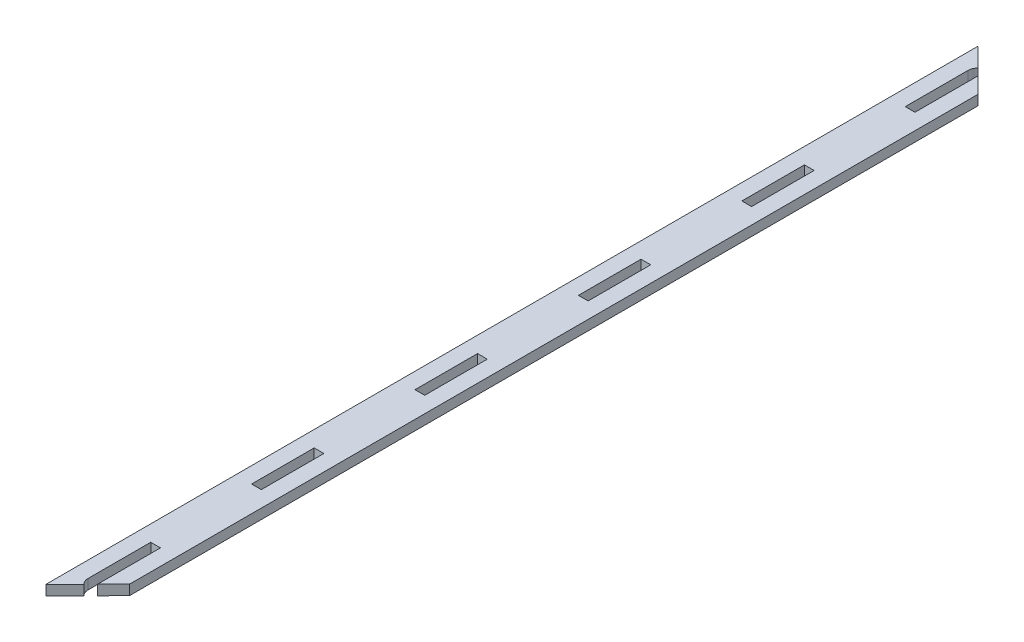
from build123d import *

# Parameters (mm, degrees)
SKETCH1_W           = 3.175
SKETCH1_H           = 20
BOSS_EXTRUDE1_DEPTH = 3.175
SKETCH10_W          = 3.09372
SKETCH10_H          = 19.91872
BOSS_EXTRUDE2_DEPTH = 3.175


with BuildPart() as part:
    # Sketch1 → Boss-Extrude1 (new body)
    with BuildSketch(Plane(origin=(0, 0, 0), x_dir=(1, 0, 0), z_dir=(0, 1, 0))):
        with BuildLine():
            Line((5.92993597, 290.47006403), (0, 296.4))
            Line((0, 296.4), (0, 0))
            Line((0, 0), (5.933366161, 5.951511012))
            ThreePointArc((5.933366161, 5.951511012), (5.242610834, 6.982741285), (5, 8.2))
            Line((5, 8.2), (5, 28.2))
            Line((5, 28.2), (8.175, 28.2))
            Line((8.175, 28.2), (8.175, 8.2))
            Line((8.175, 8.2), (13.175, 13.21529052))
            Line((13.175, 13.21529052), (13.175, 283.225))
            Line((13.175, 283.225), (8.175, 288.225))
            Line((8.175, 288.225), (8.175, 268.225))
            Line((8.175, 268.225), (5, 268.225))
            Line((5, 268.225), (5, 288.225))
            ThreePointArc((5, 288.225), (5.241682484, 289.440019898), (5.92993597, 290.47006403))
        make_face()
        with Locations((6.5875, 70.205)):
            Rectangle(SKETCH1_W, SKETCH1_H, mode=Mode.SUBTRACT)
        with Locations((6.5875, 122.21)):
            Rectangle(SKETCH1_W, SKETCH1_H, mode=Mode.SUBTRACT)
        with Locations((6.5875, 174.215)):
            Rectangle(SKETCH1_W, SKETCH1_H, mode=Mode.SUBTRACT)
        with Locations((6.5875, 226.22)):
            Rectangle(SKETCH1_W, SKETCH1_H, mode=Mode.SUBTRACT)
    extrude(amount=BOSS_EXTRUDE1_DEPTH)

    # Sketch10 → Boss-Extrude2 (add)
    with BuildSketch(Plane(origin=(0, 3.175, 0), x_dir=(1, 0, 0), z_dir=(0, 1, 0))):
        with BuildLine():
            Line((-0.04064, 296.498113639), (-0.04064, -0.098325868))
            Line((-0.04064, -0.098325868), (5.991025757, 5.95178535))
            ThreePointArc((5.991025757, 5.95178535), (5.287996872, 6.979579765), (5.04064, 8.2))
            Line((5.04064, 8.2), (5.04064, 28.15936))
            Line((5.04064, 28.15936), (8.13436, 28.15936))
            Line((8.13436, 28.15936), (8.13436, 8.101674132))
            Line((8.13436, 8.101674132), (13.21564, 13.198493215))
            Line((13.21564, 13.198493215), (13.21564, 283.241833639))
            Line((13.21564, 283.241833639), (8.13436, 288.323113639))
            Line((8.13436, 288.323113639), (8.13436, 268.26564))
            Line((8.13436, 268.26564), (5.04064, 268.26564))
            Line((5.04064, 268.26564), (5.04064, 288.225))
            ThreePointArc((5.04064, 288.225), (5.287066096, 289.443216062), (5.987595917, 290.469877722))
            Line((5.987595917, 290.469877722), (-0.04064, 296.498113639))
        make_face()
        with Locations((6.5875, 226.22)):
            Rectangle(SKETCH10_W, SKETCH10_H, mode=Mode.SUBTRACT)
        with Locations((6.5875, 174.215)):
            Rectangle(SKETCH10_W, SKETCH10_H, mode=Mode.SUBTRACT)
        with Locations((6.5875, 122.21)):
            Rectangle(SKETCH10_W, SKETCH10_H, mode=Mode.SUBTRACT)
        with Locations((6.5875, 70.205)):
            Rectangle(SKETCH10_W, SKETCH10_H, mode=Mode.SUBTRACT)
    extrude(amount=-BOSS_EXTRUDE2_DEPTH)


solid = part.part
